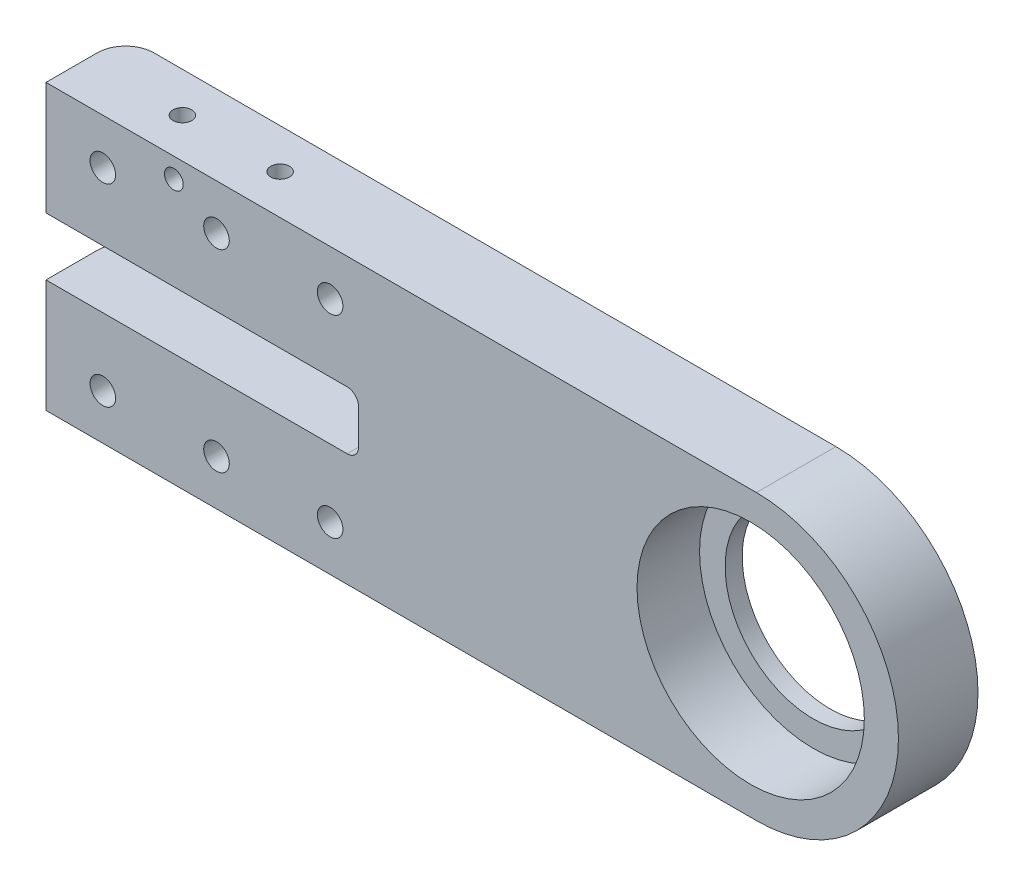
from build123d import *

# Parameters (mm, degrees)
BOSS_EXTRUDE1_DEPTH       = 14
SKETCH2_W                 = 55
SKETCH2_H                 = 10.2
CUT_EXTRUDE1_DEPTH        = 15
F_8_CLEARANCE_HOLE1_D     = 4.5
F_8_CLEARANCE_HOLE1_DEPTH = 14
F_4_CLEARANCE_HOLE1_D     = 3.3
F_4_CLEARANCE_HOLE1_DEPTH = 14
F_4_CLEARANCE_HOLE2_D     = 3.3
F_4_CLEARANCE_HOLE2_DEPTH = 19.899999999
HOLE1_D                   = 31.000000009
HOLE1_DEPTH               = 14
HOLE1_CBORE_D             = 40.00000001
HOLE1_CBORE_DEPTH         = 11
CHAMFER1_SIZE             = 2.45
FILLET1_R                 = 2
FILLET2_R                 = 5


with BuildPart() as part:
    # Sketch1 → Boss-Extrude1 (new body)
    with BuildSketch(Plane(origin=(0, 0, 0), x_dir=(-1, 0, 0), z_dir=(0, 0, -1))):
        with BuildLine():
            Line((-125, -50), (0, -50))
            Line((0, -50), (0, 0))
            Line((0, 0), (-125, 0))
            ThreePointArc((-125, 0), (-150, -25), (-125, -50))
        make_face()
    extrude(amount=-BOSS_EXTRUDE1_DEPTH)

    # Sketch2 → Cut-Extrude1 (cut, through all)
    with BuildSketch(Plane.XY.offset(14)):
        with Locations((27.5, -24.999999999)):
            Rectangle(SKETCH2_W, SKETCH2_H)
    extrude(amount=-CUT_EXTRUDE1_DEPTH, mode=Mode.SUBTRACT)

    # #8 Clearance Hole1
    with Locations(Plane(origin=(0, 0, 0), x_dir=(-1, 0, 0), z_dir=(0, 0, -1))):
        with Locations((-10, -8), (-10, -42), (-30, -42), (-30, -8), (-50, -8), (-50, -42)):
            Hole(F_8_CLEARANCE_HOLE1_D / 2, depth=F_8_CLEARANCE_HOLE1_DEPTH)

    # #4 Clearance Hole1
    with Locations(Plane.XY.offset(14)):
        with Locations((22.5, -3.5)):
            Hole(F_4_CLEARANCE_HOLE1_D / 2, depth=F_4_CLEARANCE_HOLE1_DEPTH)

    # #4 Clearance Hole2
    with Locations(Plane(origin=(0, 0, 0), x_dir=(1, 0, 0), z_dir=(0, 1, 0))):
        with Locations((17, -7), (34.2, -7)):
            Hole(F_4_CLEARANCE_HOLE2_D / 2, depth=F_4_CLEARANCE_HOLE2_DEPTH)

    # Hole1
    with Locations(Plane.XY.offset(14)):
        with Locations((123.999999995, -24.999999999)):
            CounterBoreHole(HOLE1_D / 2, HOLE1_CBORE_D / 2, HOLE1_CBORE_DEPTH, depth=HOLE1_DEPTH)

    # Chamfer1
    chamfer1_edges = [part.edges().sort_by_distance(p)[0] for p in [
        (47.75, -42, 0),
        (47.75, -8, 0),
        (27.75, -8, 0),
        (27.75, -42, 0),
        (7.75, -42, 0),
        (7.75, -8, 0),
    ]]
    chamfer(chamfer1_edges, length=CHAMFER1_SIZE)

    # Fillet1
    fillet1_edges = [part.edges().sort_by_distance(p)[0] for p in [
        (55, -19.899999999, 7),
        (55, -30.099999999, 7),
    ]]
    fillet(fillet1_edges, radius=FILLET1_R)

    # Fillet2
    fillet2_edges = [part.edges().sort_by_distance(p)[0] for p in [
        (0, -9.95, 0),
        (0, -40.05, 0),
    ]]
    fillet(fillet2_edges, radius=FILLET2_R)


solid = part.part
